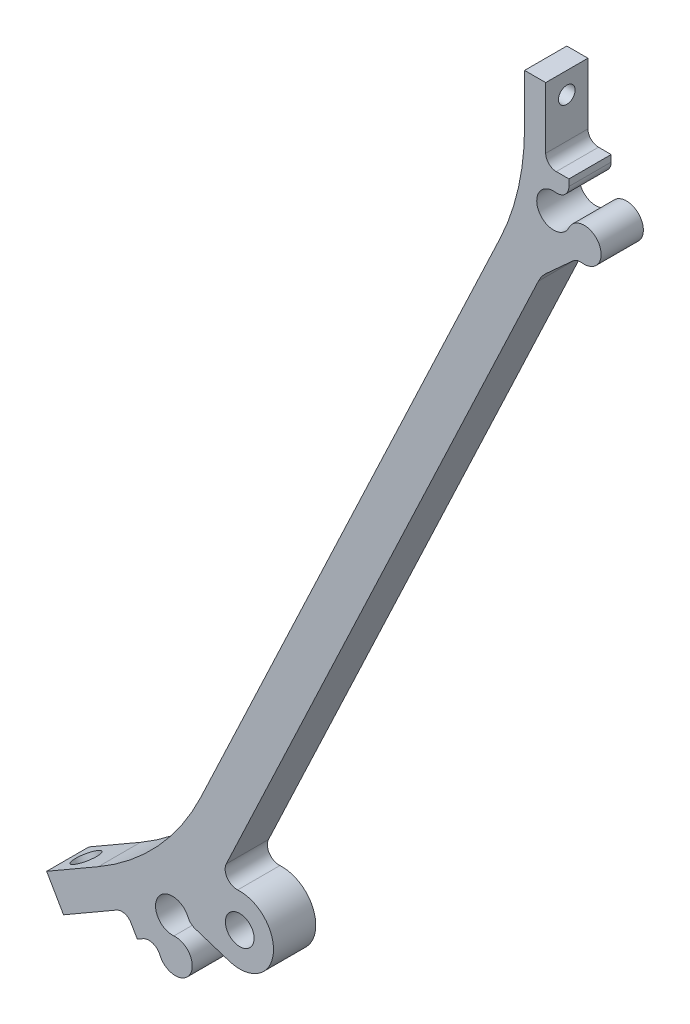
from build123d import *

# Parameters (mm, degrees)
SKETCH1_R                 = 2.159
BOSS_EXTRUDE1_DEPTH       = 6.35
SKETCH2_R                 = 1.8288
CUT_EXTRUDE1_DEPTH        = 127.508450551
SKETCH3_R                 = 0.635
CUT_EXTRUDE2_DEPTH        = 76.033777739
FILLET1_R                 = 1.5875
FILLET2_R                 = 38.1
M3X0_5_TAPPED_HOLE1_D     = 2.5
M3X0_5_TAPPED_HOLE1_DEPTH = 7.50062
M3X0_5_TAPPED_HOLE1_TIP   = 0.751075774


with BuildPart() as part:
    # Sketch1 → Boss-Extrude1 (new body)
    with BuildSketch(Plane.XY):
        with BuildLine():
            Line((15.834722261, 31.434493723), (25.183466494, 36.831993723))
            Line((25.183466494, 36.831993723), (26.929716494, 33.8074))
            Line((26.929716494, 33.8074), (27.78608986, 34.301827393))
            ThreePointArc((27.78608986, 34.301827393), (29.23868298, 34.44834582), (30.311273673, 33.457869357))
            ThreePointArc((30.311273673, 33.457869357), (34.825897026, 33.143744407), (32.428977808, 36.9824))
            ThreePointArc((32.428977808, 36.9824), (30.032058591, 40.821055593), (34.546681944, 40.506930643))
            ThreePointArc((34.546681944, 40.506930643), (34.984344673, 39.889437479), (35.639187691, 39.509928464))
            Line((35.639187691, 39.509928464), (40.774282272, 37.860721969))
            ThreePointArc((40.774282272, 37.860721969), (47.368100791, 42.064756802), (42.017768622, 47.767939879))
            ThreePointArc((42.017768622, 47.767939879), (40.437125748, 48.5456558), (40.301653082, 50.302050149))
            Line((40.301653082, 50.302050149), (87.227692295, 149.642175178))
            ThreePointArc((87.227692295, 149.642175178), (87.739785188, 150.497310852), (88.408996906, 151.235993347))
            Line((88.408996906, 151.235993347), (92.404798917, 154.858512458))
            ThreePointArc((92.404798917, 154.858512458), (93.060884875, 155.23586864), (93.814481006, 155.3061491))
            ThreePointArc((93.814481006, 155.3061491), (96.343832869, 159.058865136), (91.821, 158.9024))
            ThreePointArc((91.821, 158.9024), (87.298167131, 158.745934864), (89.827518994, 162.4986509))
            ThreePointArc((89.827518994, 162.4986509), (91.22159212, 162.932303457), (91.821, 164.263545213))
            Line((91.821, 164.263545213), (91.821, 165.2524))
            Line((91.821, 165.2524), (88.3285, 165.2524))
            Line((88.3285, 165.2524), (88.3285, 176.0474))
            Line((88.3285, 176.0474), (85.1535, 176.0474))
            Line((85.1535, 176.0474), (85.1535, 160.118189826))
            Line((85.1535, 160.118189826), (31.375529243, 46.272861553))
            Line((31.375529243, 46.272861553), (13.294722261, 35.833902774))
            Line((13.294722261, 35.833902774), (15.834722261, 31.434493723))
        make_face()
        with Locations((42.327648174, 42.6974)):
            Circle(SKETCH1_R, mode=Mode.SUBTRACT)
    extrude(amount=BOSS_EXTRUDE1_DEPTH)

    # Sketch2 → Cut-Extrude1 (cut, through all)
    with BuildSketch(Plane(origin=(-9.652854494, 16.719234422, 0), x_dir=(-0.866025404, -0.5, 0), z_dir=(0.5, -0.866025404, 0))):
        with Locations(Location((-32.605518601, -3.175, 0), (0, 0, 180))):  # turned: the seam where the file's is
            Circle(SKETCH2_R)
    extrude(amount=-CUT_EXTRUDE1_DEPTH, mode=Mode.SUBTRACT)

    # Sketch3 → Cut-Extrude2 (cut, through all)
    with BuildSketch(Plane(origin=(88.3285, 0, 0), x_dir=(0, 0, -1), z_dir=(1, 0, 0))):
        with Locations((-3.175, 172.8724)):
            Circle(SKETCH3_R)
    extrude(amount=-CUT_EXTRUDE2_DEPTH, mode=Mode.SUBTRACT)

    # Fillet1
    fillet1_edges = [part.edges().sort_by_distance(p)[0] for p in [
        (88.3285, 165.2524, 3.175),
        (25.183466494, 36.831993723, 3.175),
    ]]
    fillet(fillet1_edges, radius=FILLET1_R)

    # Fillet2
    fillet2_edges = [part.edges().sort_by_distance(p)[0] for p in [
        (31.375529243, 46.272861553, 3.175),
        (85.1535, 160.118189826, 3.175),
    ]]
    fillet(fillet2_edges, radius=FILLET2_R)

    # M3x0.5 Tapped Hole1
    with Locations(Plane.ZY.offset(-85.1535)):
        with Locations((3.175, 172.8724)):
            Hole(M3X0_5_TAPPED_HOLE1_D / 2, depth=M3X0_5_TAPPED_HOLE1_DEPTH)
            with Locations((0, 0, -(M3X0_5_TAPPED_HOLE1_DEPTH + M3X0_5_TAPPED_HOLE1_TIP / 2))):  # 118° drill point
                Cone(0, M3X0_5_TAPPED_HOLE1_D / 2, M3X0_5_TAPPED_HOLE1_TIP, mode=Mode.SUBTRACT)


solid = part.part
